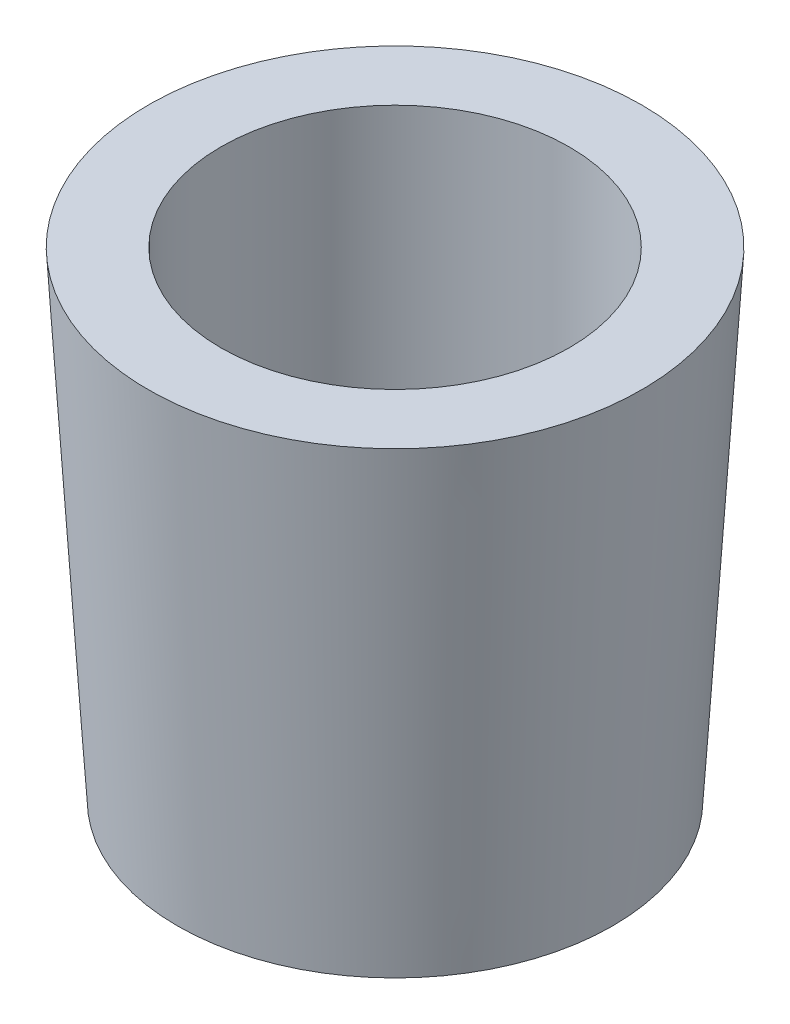
from build123d import *

# Parameters (mm, degrees)
ESBO_O2_R             = 6
CORTE_EXTRUS_O1_DEPTH = 10
ESBO_O3_R             = 5
CORTE_EXTRUS_O2_DEPTH = 4


with BuildPart() as part:
    # Esboço1 → Revolução1 (revolve)
    with BuildSketch(Plane.XY):
        Polygon((0, 0), (0, 16.5), (8.5, 16.5), (7.5, 0), align=None)
    revolve(axis=Axis((0, 0, 0), (0, 1, 0)))

    # Esboço2 → Corte-extrusão1 (cut)
    with BuildSketch(Plane(origin=(0, 16.5, 0), x_dir=(1, 0, 0), z_dir=(0, 1, 0))):
        Circle(ESBO_O2_R)
    extrude(amount=-CORTE_EXTRUS_O1_DEPTH, mode=Mode.SUBTRACT)

    # Esboço3 → Corte-extrusão2 (cut)
    with BuildSketch(Plane.XZ):
        Circle(ESBO_O3_R)
    extrude(amount=-CORTE_EXTRUS_O2_DEPTH, mode=Mode.SUBTRACT)


solid = part.part
